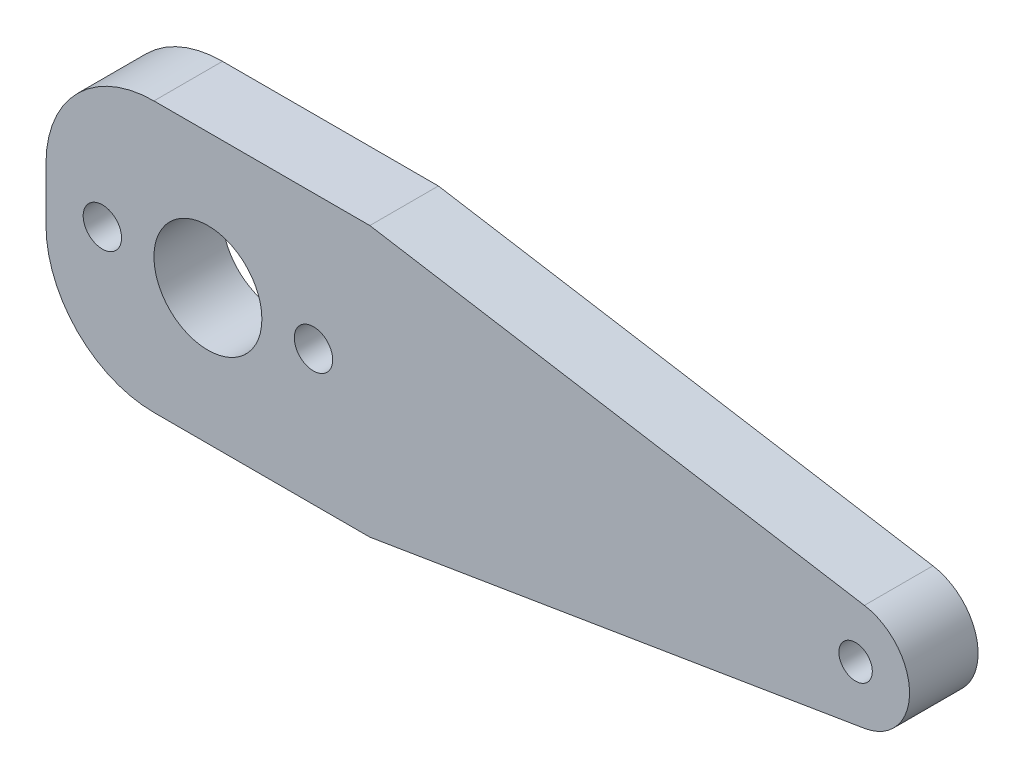
from build123d import *

# Parameters (mm, degrees)
SKETCH1_R           = 1.778
SKETCH1_R_2         = 1.55
SKETCH1_R_3         = 5
BOSS_EXTRUDE1_DEPTH = 6.35
FILLET1_R           = 10


with BuildPart() as part:
    # Sketch1 → Boss-Extrude1 (new body)
    with BuildSketch(Plane.XY):
        with BuildLine():
            Line((75.814774676, 17.433113678), (30, 25))
            Line((30, 25), (0, 25))
            Line((0, 25), (0, 0))
            Line((0, 0), (30, 0))
            Line((30, 0), (75.814763379, 7.566776682))
            ThreePointArc((75.814763379, 7.566776682), (80, 12.499940388), (75.814774676, 17.433113678))
        make_face()
        with Locations((24.779, 12.499946113)):
            Circle(SKETCH1_R, mode=Mode.SUBTRACT)
        with Locations((5.221, 12.499946113)):
            Circle(SKETCH1_R, mode=Mode.SUBTRACT)
        with Locations((75, 12.499946113)):
            Circle(SKETCH1_R_2, mode=Mode.SUBTRACT)
        with Locations((15, 12.499946113)):
            Circle(SKETCH1_R_3, mode=Mode.SUBTRACT)
    extrude(amount=BOSS_EXTRUDE1_DEPTH)

    # Fillet1
    fillet1_edges = [part.edges().sort_by_distance(p)[0] for p in [
        (0, 0, 3.175),
        (0, 25, 3.175),
    ]]
    fillet(fillet1_edges, radius=FILLET1_R)


solid = part.part
